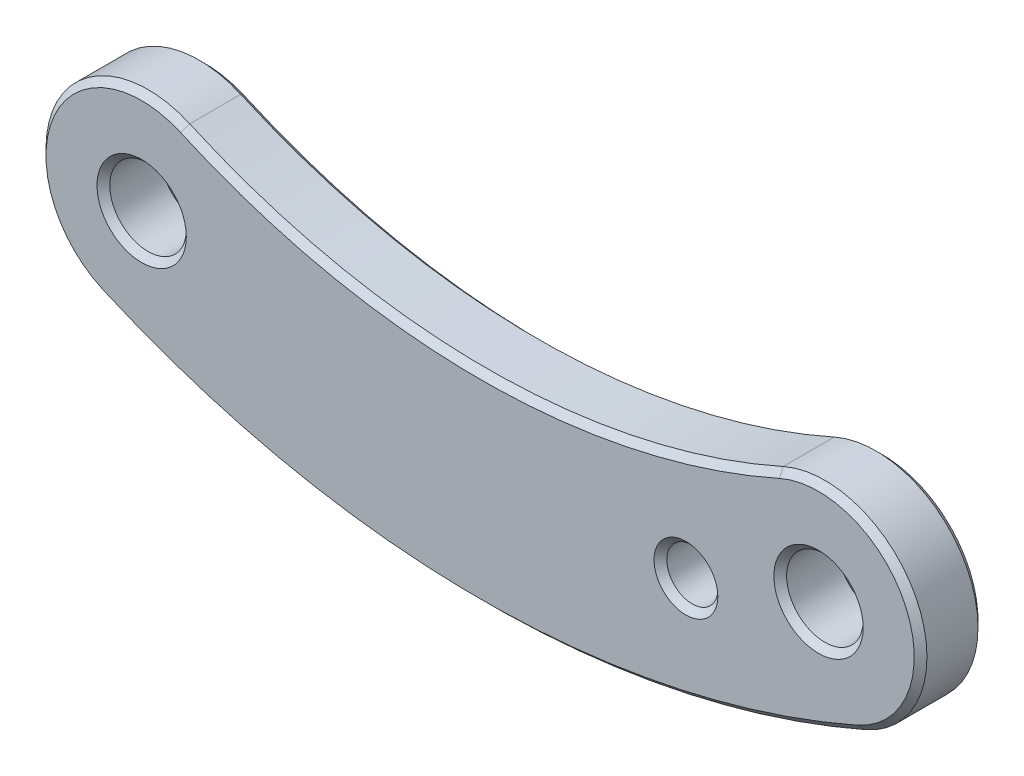
from build123d import *

# Parameters (mm, degrees)
SKETCH_1_R               = 3
EXTRUDE_1_DEPTH          = 5
CHAMFER_1_SIZE           = 0.5
SKETCH_2_R               = 2
CUT_EXTRUDE_1_DEPTH      = 1
CUT_EXTRUDE_1_DEPTH_BACK = 6
CHAMFER_2_SIZE           = 0.5


with BuildPart() as part:
    # 草图1 → 凸台-拉伸1 (new body)
    with BuildSketch(Plane.XY):
        with BuildLine():
            ThreePointArc((-56.275757576, -7.325223765), (-60.374306352, 3.240512704), (-49.794769231, 7.303305281))
            ThreePointArc((-49.794769231, 7.303305281), (-26.53, 2.339355406), (-3.265230769, 7.303305281))
            ThreePointArc((-3.265230769, 7.303305281), (7.314306352, 3.240512704), (3.215757576, -7.325223765))
            ThreePointArc((3.215757576, -7.325223765), (-26.53, -13.566903935), (-56.275757576, -7.325223765))
        make_face()
        Circle(SKETCH_1_R, mode=Mode.SUBTRACT)
        with Locations((-53.06, 0)):
            Circle(SKETCH_1_R, mode=Mode.SUBTRACT)
    extrude(amount=EXTRUDE_1_DEPTH)

    # 倒角1
    chamfer_1_edges = [part.edges().sort_by_distance(p)[0] for p in [
        (-3, 0, 0),
        (-3, 0, 5),
        (-26.53, 2.339355406, 5),
        (-56.06, 0, 0),
        (-56.06, 0, 5),
        (-60.374306352, 3.240512704, 5),
        (-26.53, -13.566903935, 5),
        (-60.374306352, 3.240512704, 0),
        (-26.53, 2.339355406, 0),
        (7.314306352, 3.240512704, 0),
        (-26.53, -13.566903935, 0),
        (7.314306352, 3.240512704, 5),
    ]]
    chamfer(chamfer_1_edges, length=CHAMFER_1_SIZE)

    # 草图2 → 切除-拉伸1 (cut, two sides)
    with BuildSketch(Plane(origin=(0, 0, 0), x_dir=(-1, 0, 0), z_dir=(0, 0, -1))) as cut_extrude_1_sk:
        with Locations((10.396009946, -3.594854266)):
            Circle(SKETCH_2_R)
    extrude(amount=CUT_EXTRUDE_1_DEPTH, mode=Mode.SUBTRACT)
    extrude(cut_extrude_1_sk.sketch, amount=-CUT_EXTRUDE_1_DEPTH_BACK, mode=Mode.SUBTRACT)

    # 倒角2
    chamfer_2_edges = [part.edges().sort_by_distance(p)[0] for p in [
        (-8.396009946, -3.594854266, 5),
        (-8.396009946, -3.594854266, 0),
    ]]
    chamfer(chamfer_2_edges, length=CHAMFER_2_SIZE)


solid = part.part
